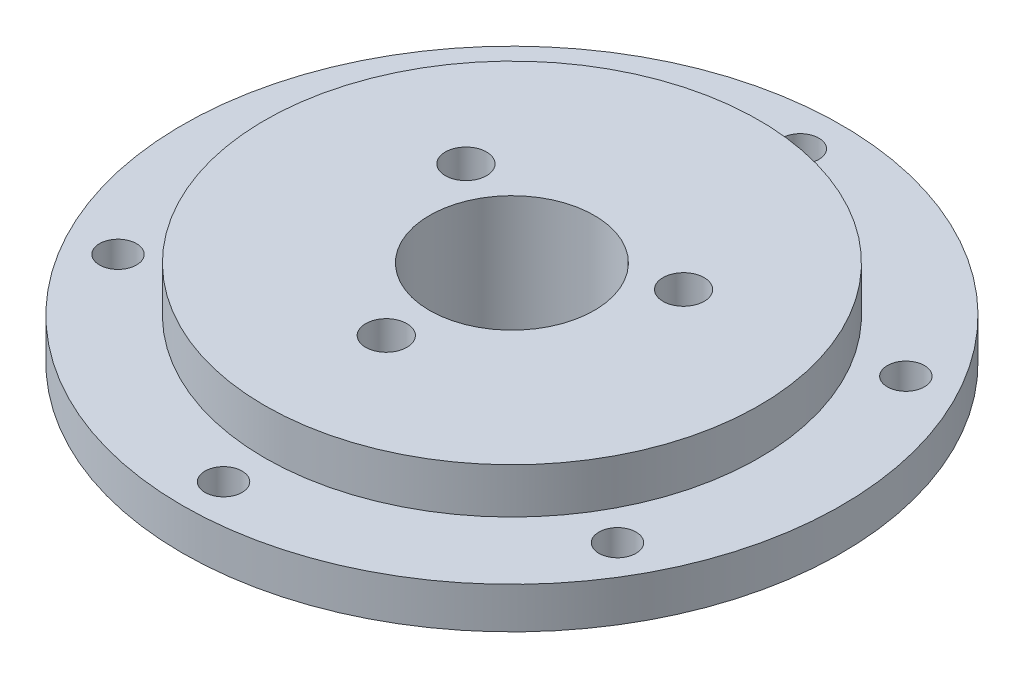
from build123d import *

# Parameters (mm, degrees)
SKETCH1_R                = 40
SKETCH1_R_2              = 2.25
BOSS_EXTRUDE1_DEPTH      = 5
SKETCH2_R                = 30
SKETCH2_R_2              = 10
SKETCH2_R_3              = 2.5
BOSS_EXTRUDE2_DEPTH      = 5.5
BOSS_EXTRUDE2_DEPTH_BACK = 10.5
SKETCH3_R                = 2.5
SKETCH3_R_2              = 10
CUT_EXTRUDE1_DEPTH       = 17


with BuildPart() as part:
    # Sketch1 → Boss-Extrude1 (new body)
    with BuildSketch(Plane(origin=(0, 0, 0), x_dir=(1, 0, 0), z_dir=(0, 1, 0))):
        Circle(SKETCH1_R)
        with Locations((0, 35)):
            Circle(SKETCH1_R_2, mode=Mode.SUBTRACT)
        with Locations((30.310889132, 17.5)):
            Circle(SKETCH1_R_2, mode=Mode.SUBTRACT)
        with Locations((30.310889132, -17.5)):
            Circle(SKETCH1_R_2, mode=Mode.SUBTRACT)
        with Locations((0, -35)):
            Circle(SKETCH1_R_2, mode=Mode.SUBTRACT)
        with Locations((-30.310889132, -17.5)):
            Circle(SKETCH1_R_2, mode=Mode.SUBTRACT)
        with Locations((-30.310889132, 17.5)):
            Circle(SKETCH1_R_2, mode=Mode.SUBTRACT)
    extrude(amount=BOSS_EXTRUDE1_DEPTH)

    # Sketch2 → Boss-Extrude2 (add, two sides)
    with BuildSketch(Plane(origin=(0, 5, 0), x_dir=(1, 0, 0), z_dir=(0, 1, 0))) as boss_extrude2_sk:
        Circle(SKETCH2_R)
        Circle(SKETCH2_R_2, mode=Mode.SUBTRACT)
        with Locations((0, -15.25)):
            Circle(SKETCH2_R_3, mode=Mode.SUBTRACT)
        with Locations((-13.206887408, 7.625)):
            Circle(SKETCH2_R_3, mode=Mode.SUBTRACT)
        with Locations((13.206887408, 7.625)):
            Circle(SKETCH2_R_3, mode=Mode.SUBTRACT)
    extrude(amount=BOSS_EXTRUDE2_DEPTH)
    extrude(boss_extrude2_sk.sketch, amount=-BOSS_EXTRUDE2_DEPTH_BACK)

    # Sketch3 → Cut-Extrude1 (cut, through all)
    with BuildSketch(Plane(origin=(0, 10.5, 0), x_dir=(1, 0, 0), z_dir=(0, 1, 0))):
        with Locations((0, -15.25)):
            Circle(SKETCH3_R)
        with Locations((13.206887408, 7.625)):
            Circle(SKETCH3_R)
        Circle(SKETCH3_R_2)
        with Locations((-13.206887408, 7.625)):
            Circle(SKETCH3_R)
    extrude(amount=-CUT_EXTRUDE1_DEPTH, mode=Mode.SUBTRACT)


solid = part.part
